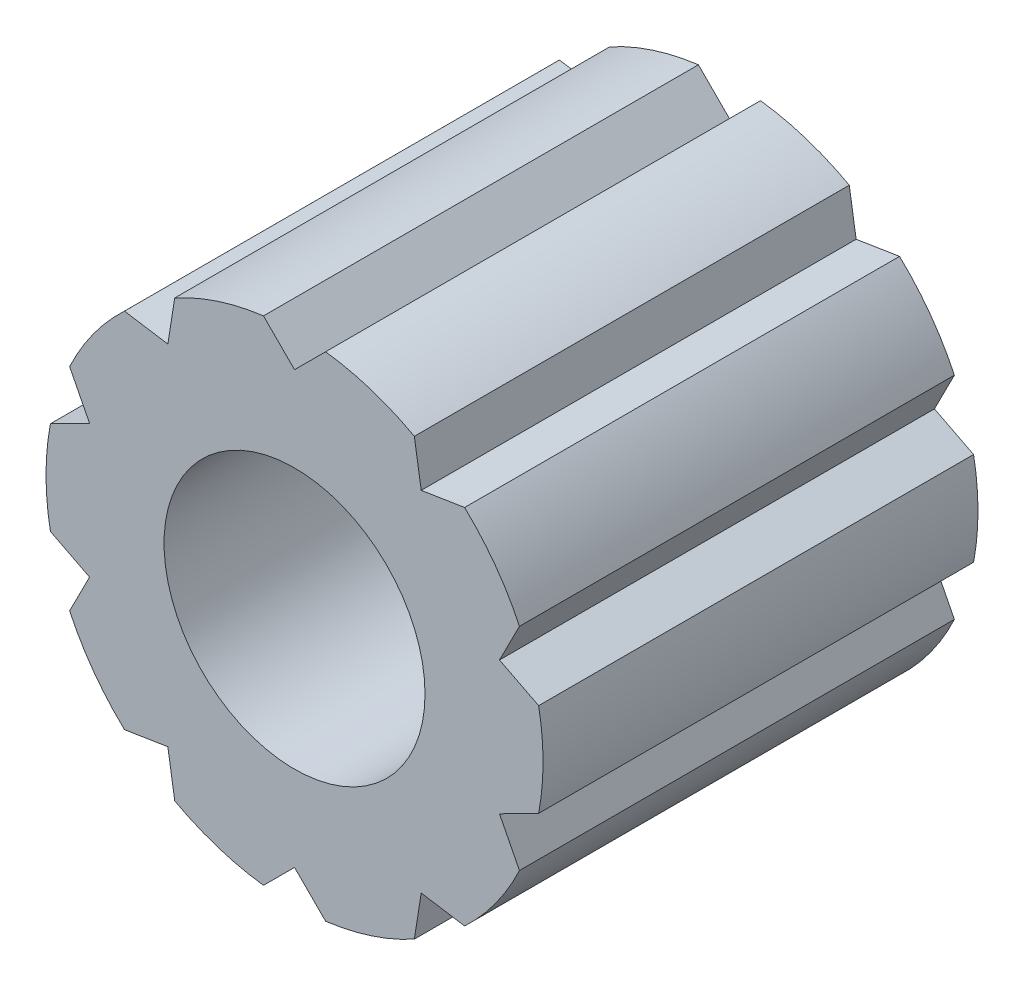
from build123d import *

# Parameters (mm, degrees)
SKETCH1_R           = 2.1
BOSS_EXTRUDE1_DEPTH = 7


with BuildPart() as part:
    # Sketch1 → Boss-Extrude1 (new body)
    with BuildSketch(Plane.XY):
        with BuildLine():
            Line((0.5, 3.968626967), (0, 3.468626967))
            Line((0, 3.468626967), (-0.5, 3.968626967))
            ThreePointArc((-0.5, 3.968626967), (-1.236067977, 3.804226065), (-1.928191906, 3.504579286))
            Line((-1.928191906, 3.504579286), (-2.038807777, 2.806178163))
            Line((-2.038807777, 2.806178163), (-2.7372089, 2.916794034))
            ThreePointArc((-2.7372089, 2.916794034), (-3.236067977, 2.351141009), (-3.61988004, 1.701901435))
            Line((-3.61988004, 1.701901435), (-3.298860279, 1.07186468))
            Line((-3.298860279, 1.07186468), (-3.928897035, 0.750844919))
            ThreePointArc((-3.928897035, 0.750844919), (-4, 0), (-3.928897035, -0.750844919))
            Line((-3.928897035, -0.750844919), (-3.298860279, -1.07186468))
            Line((-3.298860279, -1.07186468), (-3.61988004, -1.701901435))
            ThreePointArc((-3.61988004, -1.701901435), (-3.236067977, -2.351141009), (-2.7372089, -2.916794034))
            Line((-2.7372089, -2.916794034), (-2.038807777, -2.806178163))
            Line((-2.038807777, -2.806178163), (-1.928191906, -3.504579286))
            ThreePointArc((-1.928191906, -3.504579286), (-1.236067977, -3.804226065), (-0.5, -3.968626967))
            Line((-0.5, -3.968626967), (0, -3.468626967))
            Line((0, -3.468626967), (0.5, -3.968626967))
            ThreePointArc((0.5, -3.968626967), (1.236067977, -3.804226065), (1.928191906, -3.504579286))
            Line((1.928191906, -3.504579286), (2.038807777, -2.806178163))
            Line((2.038807777, -2.806178163), (2.7372089, -2.916794034))
            ThreePointArc((2.7372089, -2.916794034), (3.236067977, -2.351141009), (3.61988004, -1.701901435))
            Line((3.61988004, -1.701901435), (3.298860279, -1.07186468))
            Line((3.298860279, -1.07186468), (3.928897035, -0.750844919))
            ThreePointArc((3.928897035, -0.750844919), (4, 0), (3.928897035, 0.750844919))
            Line((3.928897035, 0.750844919), (3.298860279, 1.07186468))
            Line((3.298860279, 1.07186468), (3.61988004, 1.701901435))
            ThreePointArc((3.61988004, 1.701901435), (3.236067977, 2.351141009), (2.7372089, 2.916794034))
            Line((2.7372089, 2.916794034), (2.038807777, 2.806178163))
            Line((2.038807777, 2.806178163), (1.928191906, 3.504579286))
            ThreePointArc((1.928191906, 3.504579286), (1.236067977, 3.804226065), (0.5, 3.968626967))
        make_face()
        Circle(SKETCH1_R, mode=Mode.SUBTRACT)
    extrude(amount=BOSS_EXTRUDE1_DEPTH)


solid = part.part
